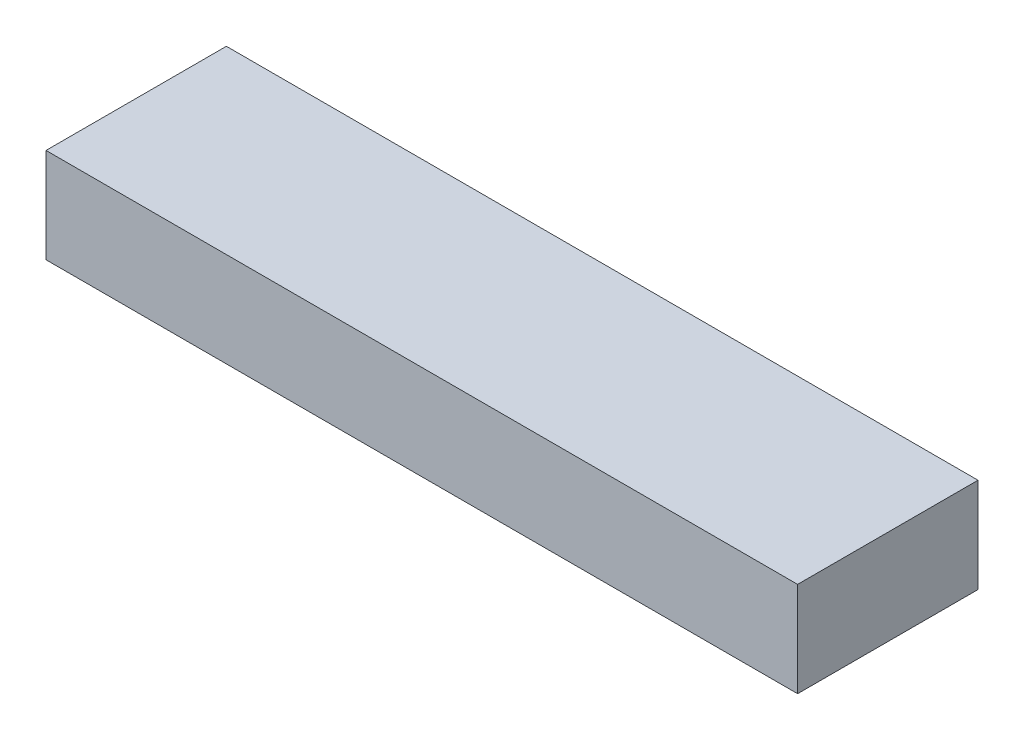
from build123d import *

# Parameters (mm, degrees)
SKETCH1_W           = 25
SKETCH1_H           = 6
BOSS_EXTRUDE1_DEPTH = 3.15


with BuildPart() as part:
    # Sketch1 → Boss-Extrude1 (new body)
    with BuildSketch(Plane(origin=(0, 0, 0), x_dir=(1, 0, 0), z_dir=(0, 1, 0))):
        Rectangle(SKETCH1_W, SKETCH1_H)
    extrude(amount=BOSS_EXTRUDE1_DEPTH)


solid = part.part
